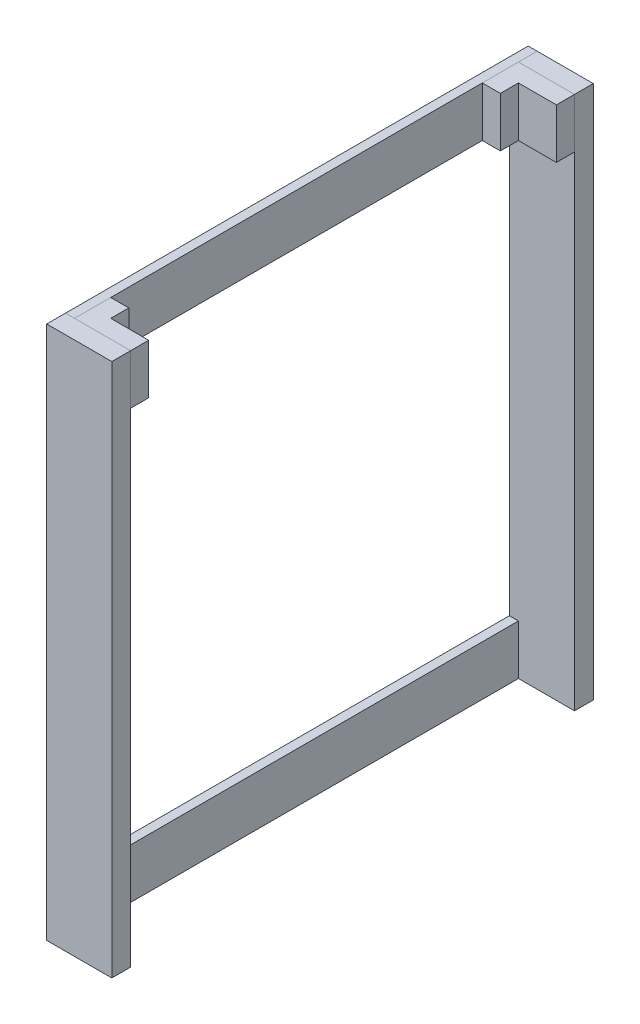
from build123d import *

# Parameters (mm, degrees)
BOSS_EXTRUDE1_START   = 130
SKETCH3_W             = 90
SKETCH3_H             = 26
BOSS_EXTRUDE1_DEPTH   = 738.5
BOSS_EXTRUDE1_2_DEPTH = 738.5
BOSS_EXTRUDE2_START   = -333
SKETCH5_W             = 12.5
SKETCH5_H             = 69
BOSS_EXTRUDE2_DEPTH   = 666
BOSS_EXTRUDE2_2_DEPTH = 666
BOSS_EXTRUDE3_DEPTH   = 69
BOSS_EXTRUDE3_2_DEPTH = 69


with BuildPart() as part:
    # Sketch3 → Boss-Extrude1 (new body)
    with BuildSketch(Plane(origin=(0, -900, 0), x_dir=(-1, 0, 0), z_dir=(0, 1, 0)).offset(BOSS_EXTRUDE1_START)):
        with Locations((655, 320)):
            Rectangle(SKETCH3_W, SKETCH3_H)
    extrude(amount=BOSS_EXTRUDE1_DEPTH)


with BuildPart() as body_2:
    # Sketch3 → Boss-Extrude1 2 (new body)
    with BuildSketch(Plane(origin=(0, -900, 0), x_dir=(-1, 0, 0), z_dir=(0, 1, 0)).offset(BOSS_EXTRUDE1_START)):
        with Locations((655, -320)):
            Rectangle(SKETCH3_W, SKETCH3_H)
    extrude(amount=BOSS_EXTRUDE1_2_DEPTH)


with BuildPart() as body_3:
    # Sketch5 → Boss-Extrude2 (new body)
    with BuildSketch(Plane.XY.offset(BOSS_EXTRUDE2_START)):
        with Locations((-693.75, -66)):
            Rectangle(SKETCH5_W, SKETCH5_H)
    extrude(amount=BOSS_EXTRUDE2_DEPTH)


with BuildPart() as body_4:
    # Sketch5 → Boss-Extrude2 2 (new body)
    with BuildSketch(Plane.XY.offset(BOSS_EXTRUDE2_START)):
        with Locations((-693.75, -735.5)):
            Rectangle(SKETCH5_W, SKETCH5_H)
    extrude(amount=BOSS_EXTRUDE2_2_DEPTH)


with BuildPart() as body_5:
    # Sketch7 → Boss-Extrude3 (new body)
    with BuildSketch(Plane(origin=(0, -31.5, 0), x_dir=(1, 0, 0), z_dir=(0, 1, 0))):
        Polygon((-610, 307), (-687.5, 307), (-687.5, 282), (-687.5, 257), (-662.5, 257), (-662.5, 282), (-610, 282), align=None)
    extrude(amount=-BOSS_EXTRUDE3_DEPTH)


with BuildPart() as body_6:
    # Sketch7 → Boss-Extrude3 2 (new body)
    with BuildSketch(Plane(origin=(0, -31.5, 0), x_dir=(1, 0, 0), z_dir=(0, 1, 0))):
        Polygon((-610, -307), (-687.5, -307), (-687.5, -282), (-687.5, -257), (-662.5, -257), (-662.5, -282), (-610, -282), align=None)
    extrude(amount=-BOSS_EXTRUDE3_2_DEPTH)


solid = Compound([part.part, body_2.part, body_3.part, body_4.part, body_5.part, body_6.part])
